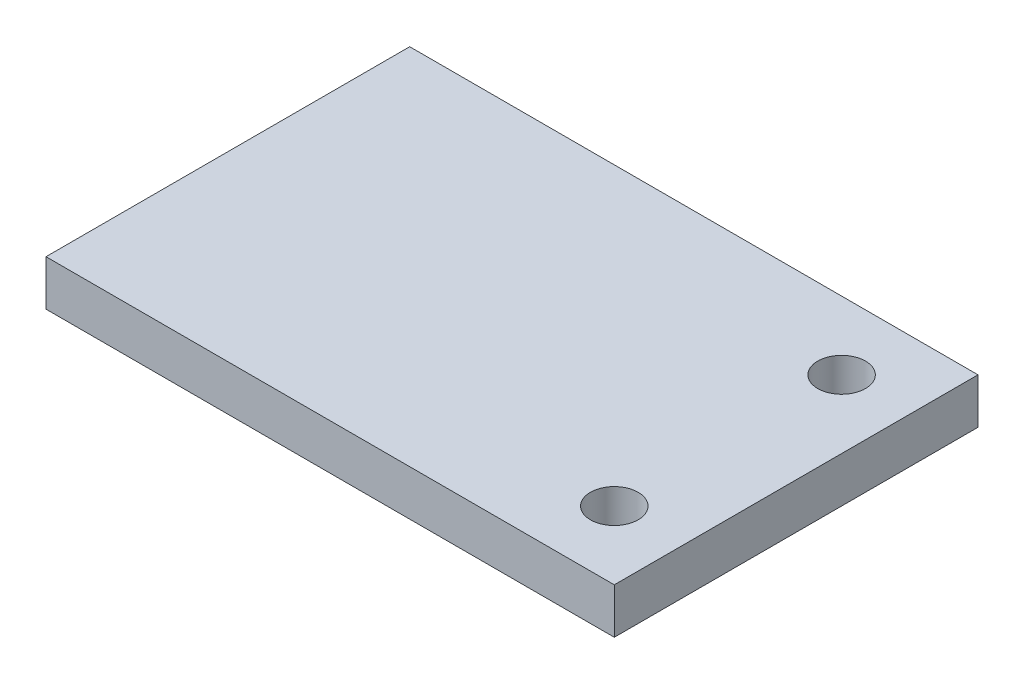
from build123d import *

# Parameters (mm, degrees)
SKETCH1_W           = 125
SKETCH1_H           = 80
SKETCH1_R           = 5.25
BOSS_EXTRUDE1_DEPTH = 10


with BuildPart() as part:
    # Sketch1 → Boss-Extrude1 (new body)
    with BuildSketch(Plane(origin=(0, 0, 0), x_dir=(1, 0, 0), z_dir=(0, 1, 0))):
        with Locations((52.5, 25)):
            Rectangle(SKETCH1_W, SKETCH1_H)
        with Locations((100, 50)):
            Circle(SKETCH1_R, mode=Mode.SUBTRACT)
        with Locations((100, 0)):
            Circle(SKETCH1_R, mode=Mode.SUBTRACT)
    extrude(amount=BOSS_EXTRUDE1_DEPTH)


solid = part.part
